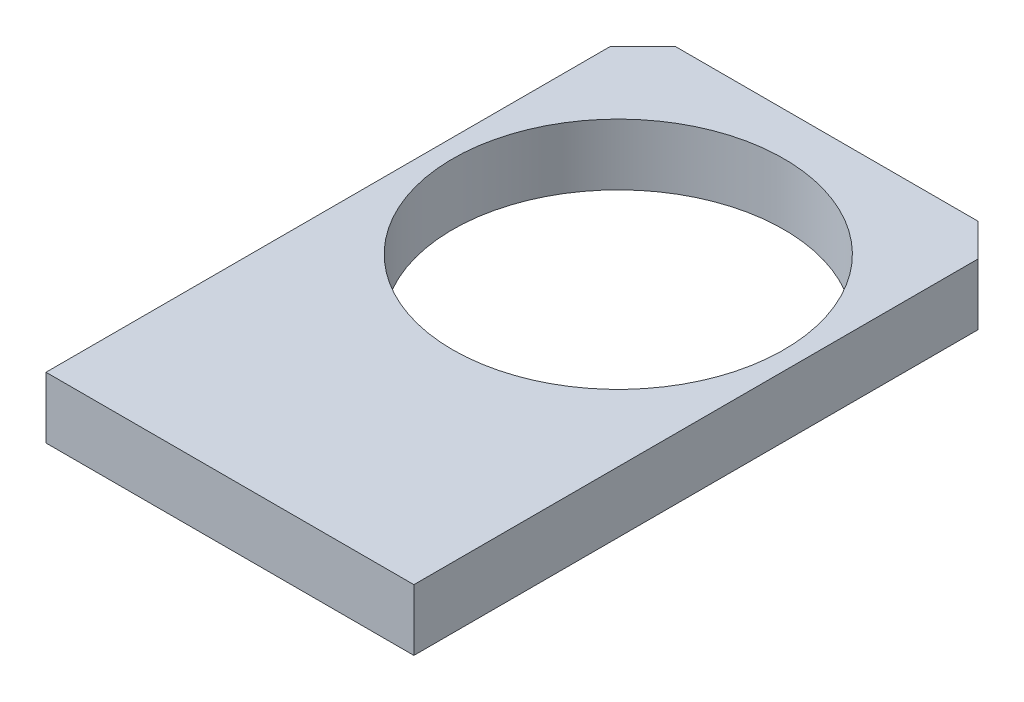
from build123d import *

# Parameters (mm, degrees)
SKETCH1_W           = 45
SKETCH1_H           = 73
SKETCH1_R           = 20.25
BOSS_EXTRUDE1_DEPTH = 7.5
CHAMFER1_SIZE       = 4


with BuildPart() as part:
    # Sketch1 → Boss-Extrude1 (new body)
    with BuildSketch(Plane(origin=(0, 0, 0), x_dir=(1, 0, 0), z_dir=(0, 1, 0))):
        with Locations((0, 36.5)):
            Rectangle(SKETCH1_W, SKETCH1_H)
        with Locations((0, 47.5)):
            Circle(SKETCH1_R, mode=Mode.SUBTRACT)
    extrude(amount=BOSS_EXTRUDE1_DEPTH)

    # Chamfer1
    chamfer1_edges = [part.edges().sort_by_distance(p)[0] for p in [
        (-22.5, 3.75, -73),
        (22.5, 3.75, -73),
    ]]
    chamfer(chamfer1_edges, length=CHAMFER1_SIZE)


solid = part.part
